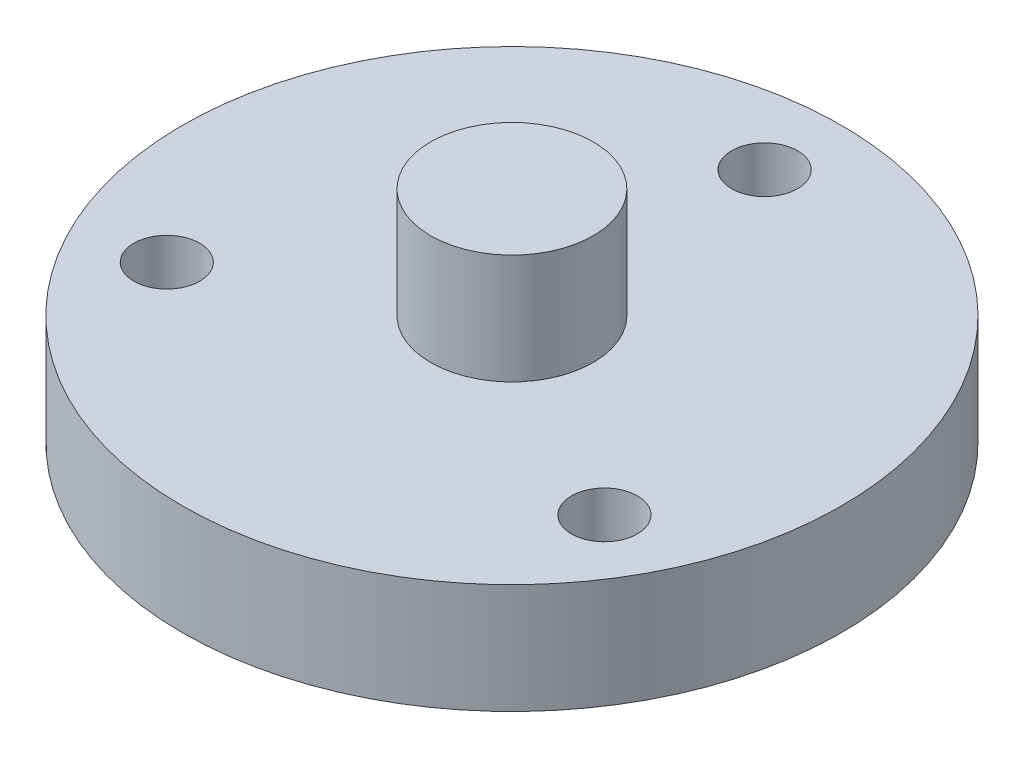
from build123d import *

# Parameters (mm, degrees)
ESQUISSE3_R             = 3
ENL_V_MAT_EXTRU_1_DEPTH = 11


with BuildPart() as part:
    # Esquisse1 → Révolution1 (revolve)
    with BuildSketch(Plane.XY, mode=Mode.PRIVATE) as r_volution1_sk:
        Polygon((0, 0), (30, 0), (30, 10), (7.4, 10), (7.4, 20), (0, 20), align=None)
    revolve(r_volution1_sk.sketch.rotate(Axis((0, 30.251396648, 0), (0, -1, 0)), 90), axis=Axis((0, 30.251396648, 0), (0, -1, 0)))  # turned: the seam where the file's is

    # Esquisse3 → Enlèv. mat.-Extru.1 (cut, through all)
    with BuildSketch(Plane(origin=(0, 10, 0), x_dir=(1, 0, 0), z_dir=(0, 1, 0))):
        with Locations(Location((0, 23, 0), (0, 0, 270))):  # turned: the seam where the file's is
            Circle(ESQUISSE3_R)
        with Locations(Location((19.918584287, -11.5, 0), (0, 0, 270))):  # turned: the seam where the file's is
            Circle(ESQUISSE3_R)
        with Locations(Location((-19.918584287, -11.5, 0), (0, 0, 270))):  # turned: the seam where the file's is
            Circle(ESQUISSE3_R)
    extrude(amount=-ENL_V_MAT_EXTRU_1_DEPTH, mode=Mode.SUBTRACT)


solid = part.part
